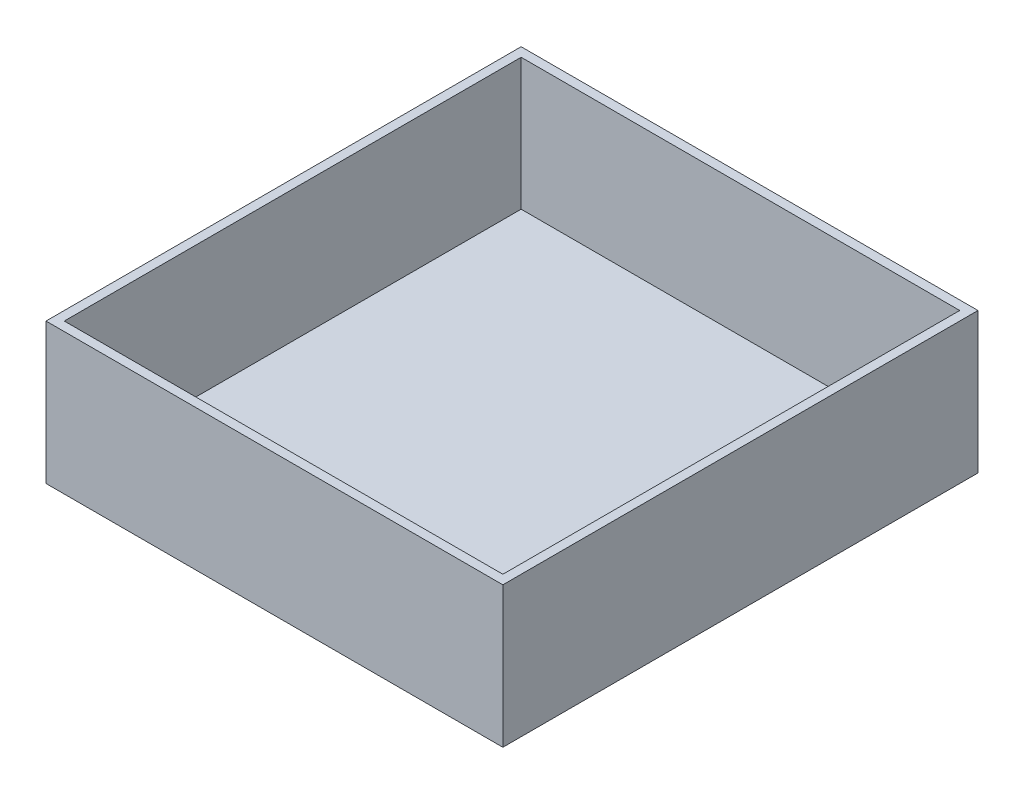
from build123d import *

# Parameters (mm, degrees)
SKETCH1_W           = 158.75
SKETCH1_H           = 165.1
BOSS_EXTRUDE1_DEPTH = 3.175
SKETCH2_W           = 158.75
SKETCH2_H           = 165.1
SKETCH2_W_2         = 152.4
SKETCH2_H_2         = 158.75
BOSS_EXTRUDE2_DEPTH = 45.72


with BuildPart() as part:
    # Sketch1 → Boss-Extrude1 (new body)
    with BuildSketch(Plane(origin=(0, 0, 0), x_dir=(1, 0, 0), z_dir=(0, 1, 0))):
        Rectangle(SKETCH1_W, SKETCH1_H)
    extrude(amount=BOSS_EXTRUDE1_DEPTH)

    # Sketch2 → Boss-Extrude2 (add)
    with BuildSketch(Plane(origin=(0, 3.175, 0), x_dir=(1, 0, 0), z_dir=(0, 1, 0))):
        Rectangle(SKETCH2_W, SKETCH2_H)
        Rectangle(SKETCH2_W_2, SKETCH2_H_2, mode=Mode.SUBTRACT)
    extrude(amount=BOSS_EXTRUDE2_DEPTH)


solid = part.part
